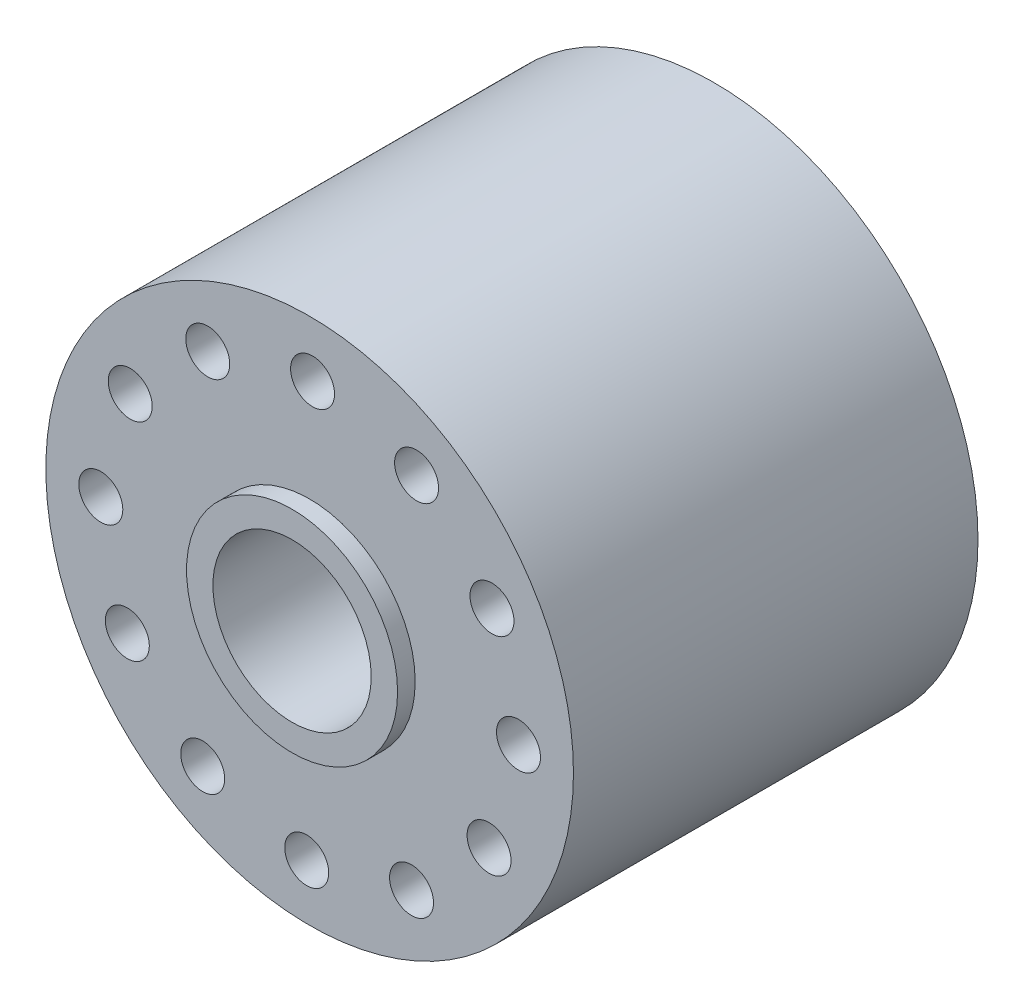
from build123d import *

# Parameters (mm, degrees)
SKETCH1_R           = 30
SKETCH1_R_2         = 12
SKETCH1_R_3         = 2.5
BOSS_EXTRUDE1_DEPTH = 23
SKETCH2_R           = 12
SKETCH2_R_2         = 9
BOSS_EXTRUDE2_DEPTH = 25


with BuildPart() as part:
    # Sketch1 → Boss-Extrude1 (new body, symmetric)
    with BuildSketch(Plane.XY):
        Circle(SKETCH1_R)
        Circle(SKETCH1_R_2, mode=Mode.SUBTRACT)
        with Locations((0.330787081, 23.747696307)):
            Circle(SKETCH1_R_3, mode=Mode.SUBTRACT)
        with Locations((12.160318169, 20.400714743)):
            Circle(SKETCH1_R_3, mode=Mode.SUBTRACT)
        with Locations((20.731501824, 11.587378139)):
            Circle(SKETCH1_R_3, mode=Mode.SUBTRACT)
        with Locations((23.747696307, -0.330787081)):
            Circle(SKETCH1_R_3, mode=Mode.SUBTRACT)
        with Locations((20.400714743, -12.160318169)):
            Circle(SKETCH1_R_3, mode=Mode.SUBTRACT)
        with Locations((11.587378139, -20.731501824)):
            Circle(SKETCH1_R_3, mode=Mode.SUBTRACT)
        with Locations((-0.330787081, -23.747696307)):
            Circle(SKETCH1_R_3, mode=Mode.SUBTRACT)
        with Locations((-12.160318169, -20.400714743)):
            Circle(SKETCH1_R_3, mode=Mode.SUBTRACT)
        with Locations((-20.731501824, -11.587378139)):
            Circle(SKETCH1_R_3, mode=Mode.SUBTRACT)
        with Locations((-23.747696307, 0.330787081)):
            Circle(SKETCH1_R_3, mode=Mode.SUBTRACT)
        with Locations((-20.400714743, 12.160318169)):
            Circle(SKETCH1_R_3, mode=Mode.SUBTRACT)
        with Locations((-11.587378139, 20.731501824)):
            Circle(SKETCH1_R_3, mode=Mode.SUBTRACT)
    extrude(amount=BOSS_EXTRUDE1_DEPTH, both=True)

    # Sketch2 → Boss-Extrude2 (add, symmetric)
    with BuildSketch(Plane.XY):
        Circle(SKETCH2_R)
        Circle(SKETCH2_R_2, mode=Mode.SUBTRACT)
    extrude(amount=BOSS_EXTRUDE2_DEPTH, both=True)


solid = part.part
